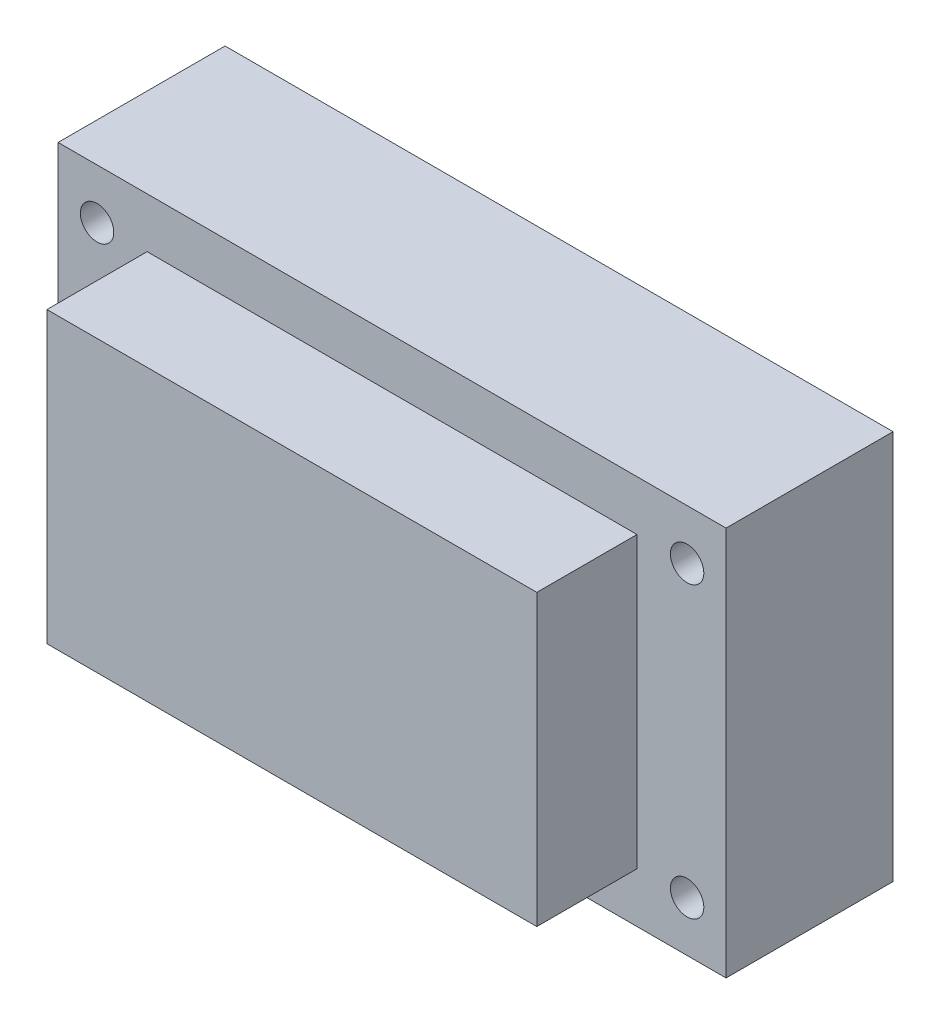
from build123d import *

# Parameters (mm, degrees)
CROQUIS1_W              = 44
CROQUIS1_H              = 26
SALIENTE_EXTRUIR1_DEPTH = 9
CROQUIS2_W              = 60
CROQUIS2_H              = 35
CROQUIS2_R              = 1.5
SALIENTE_EXTRUIR2_DEPTH = 15


with BuildPart() as part:
    # Croquis1 → Saliente-Extruir1 (new body)
    with BuildSketch(Plane.XY):
        with Locations((22, 13)):
            Rectangle(CROQUIS1_W, CROQUIS1_H)
    extrude(amount=SALIENTE_EXTRUIR1_DEPTH)

    # Croquis2 → Saliente-Extruir2 (add)
    with BuildSketch(Plane(origin=(0, 0, 0), x_dir=(-1, 0, 0), z_dir=(0, 0, -1))):
        with Locations((-22, 13)):
            Rectangle(CROQUIS2_W, CROQUIS2_H)
        with Locations((-48.5, 26)):
            Circle(CROQUIS2_R, mode=Mode.SUBTRACT)
        with Locations((4.5, 26)):
            Circle(CROQUIS2_R, mode=Mode.SUBTRACT)
        with Locations((-48.5, 0)):
            Circle(CROQUIS2_R, mode=Mode.SUBTRACT)
        with Locations((4.5, 0)):
            Circle(CROQUIS2_R, mode=Mode.SUBTRACT)
    extrude(amount=SALIENTE_EXTRUIR2_DEPTH)


solid = part.part
